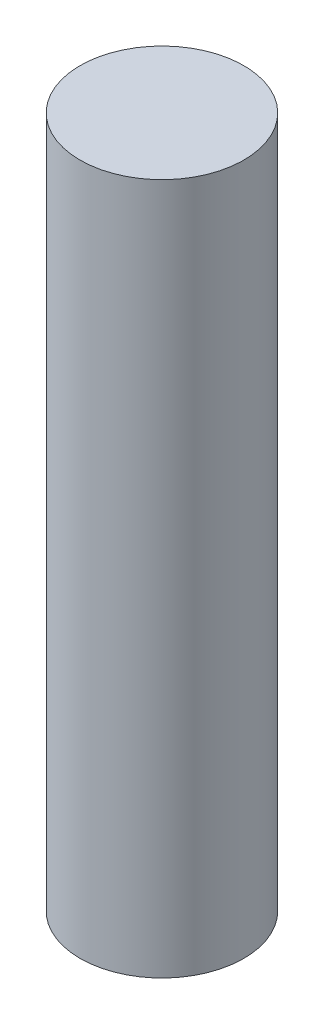
from build123d import *

# Parameters (mm, degrees)
SKETCH1_R           = 9
BOSS_EXTRUDE1_DEPTH = 76


with BuildPart() as part:
    # Sketch1 → Boss-Extrude1 (new body)
    with BuildSketch(Plane(origin=(0, 0, 0), x_dir=(1, 0, 0), z_dir=(0, 1, 0))):
        Circle(SKETCH1_R)
    extrude(amount=BOSS_EXTRUDE1_DEPTH)


solid = part.part
